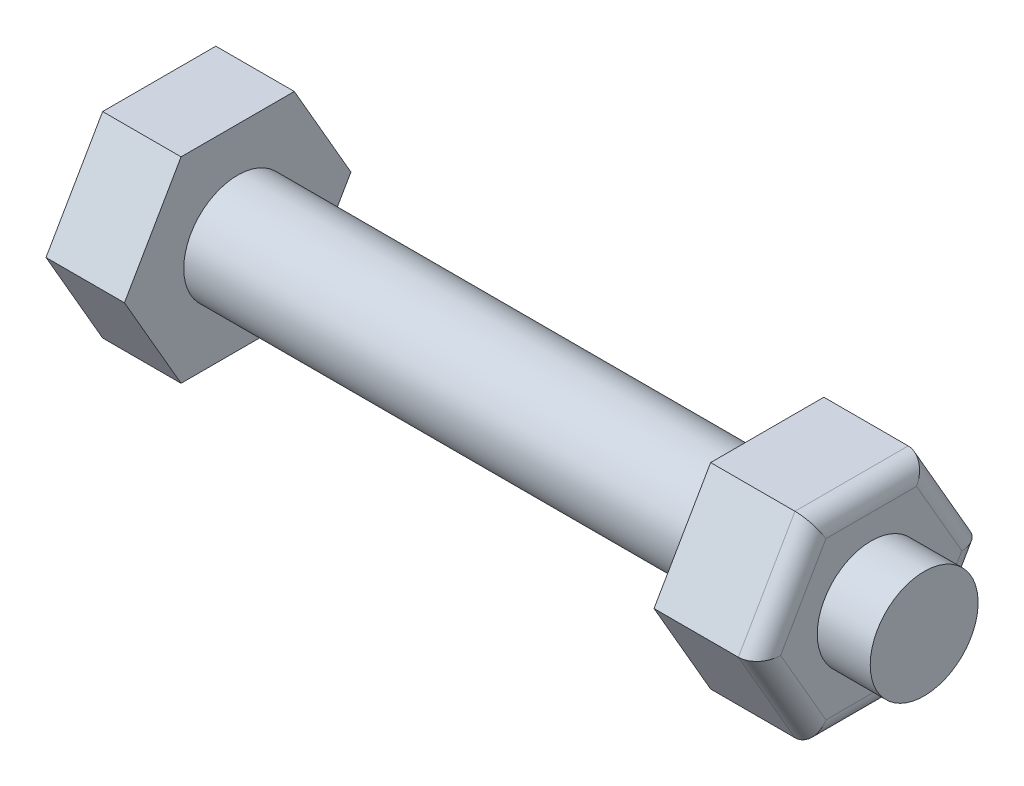
from build123d import *

# Parameters (mm, degrees)
SKETCH1_W           = 35
SKETCH1_H           = 2.75
BOSS_EXTRUDE1_DEPTH = 4
BOSS_EXTRUDE2_DEPTH = 5.3
FILLET1_R           = 1


with BuildPart() as part:
    # Sketch1 → Revolve1 (revolve)
    with BuildSketch(Plane.XY):
        with Locations((17.5, 1.375)):
            Rectangle(SKETCH1_W, SKETCH1_H)
    revolve(axis=Axis((0, 0, 0), (1, 0, 0)))

    # Sketch2 → Boss-Extrude1 (add)
    with BuildSketch(Plane(origin=(0, 0, 0), x_dir=(0, 0, -1), z_dir=(1, 0, 0))):
        Polygon((5.773502692, 0), (2.886751346, 5), (-2.886751346, 5), (-5.773502692, 0), (-2.886751346, -5), (2.886751346, -5), align=None)
    extrude(amount=-BOSS_EXTRUDE1_DEPTH)

    # Sketch3 → Boss-Extrude2 (add)
    with BuildSketch(Plane(origin=(27, 0, 0), x_dir=(0, 0, -1), z_dir=(1, 0, 0))):
        Polygon((5.773502692, 0), (2.886751346, 5), (-2.886751346, 5), (-5.773502692, 0), (-2.886751346, -5), (2.886751346, -5), align=None)
    extrude(amount=BOSS_EXTRUDE2_DEPTH)

    # Fillet1
    fillet1_edges = [part.edges().sort_by_distance(p)[0] for p in [
        (32.3, 2.5, -4.330127019),
        (32.3, -2.5, -4.330127019),
        (32.3, -5, 0),
        (32.3, -2.5, 4.330127019),
        (32.3, 2.5, 4.330127019),
        (32.3, 5, 0),
    ]]
    fillet(fillet1_edges, radius=FILLET1_R)


solid = part.part
